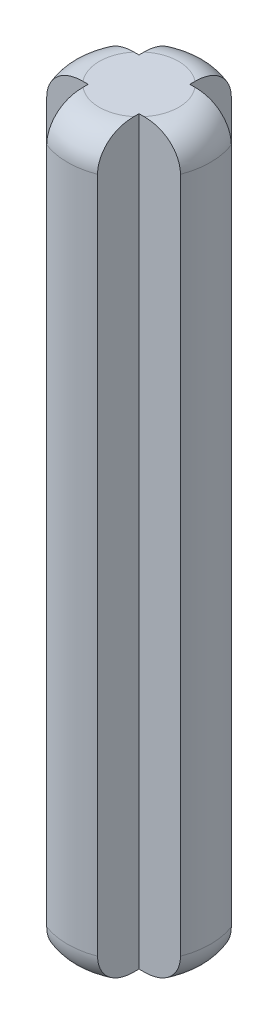
from build123d import *

# Parameters (mm, degrees)
BOSS_EXTRUDE1_DEPTH = 23.3
FILLET1_R           = 1
FILLET2_R           = 1
FILLET3_R           = 1
FILLET4_R           = 1
FILLET20_R          = 1
FILLET21_R          = 1
FILLET22_R          = 1
FILLET23_R          = 1


with BuildPart() as part:
    # Sketch1 → Boss-Extrude1 (new body)
    with BuildSketch(Plane(origin=(0, 0, 0), x_dir=(1, 0, 0), z_dir=(0, 1, 0))):
        with BuildLine():
            Line((-0.8, -0.8), (-0.8, -2.102974084))
            ThreePointArc((-0.8, -2.102974084), (0, -2.25), (0.8, -2.102974084))
            Line((0.8, -2.102974084), (0.8, -0.8))
            Line((0.8, -0.8), (2.102974084, -0.8))
            ThreePointArc((2.102974084, -0.8), (2.25, 0), (2.102974084, 0.8))
            Line((2.102974084, 0.8), (0.8, 0.8))
            Line((0.8, 0.8), (0.8, 2.102974084))
            ThreePointArc((0.8, 2.102974084), (0, 2.25), (-0.8, 2.102974084))
            Line((-0.8, 2.102974084), (-0.8, 0.8))
            Line((-0.8, 0.8), (-2.102974084, 0.8))
            ThreePointArc((-2.102974084, 0.8), (-2.25, 0), (-2.102974084, -0.8))
            Line((-2.102974084, -0.8), (-0.8, -0.8))
        make_face()
    extrude(amount=BOSS_EXTRUDE1_DEPTH)

    # Fillet1
    fillet1_edges = [part.edges().sort_by_distance(p)[0] for p in [
        (-2.25, 0, 0),
    ]]
    fillet(fillet1_edges, radius=FILLET1_R)

    # Fillet2
    fillet2_edges = [part.edges().sort_by_distance(p)[0] for p in [
        (0, 0, 2.25),
    ]]
    fillet(fillet2_edges, radius=FILLET2_R)

    # Fillet3
    fillet3_edges = [part.edges().sort_by_distance(p)[0] for p in [
        (2.25, 0, 0),
    ]]
    fillet(fillet3_edges, radius=FILLET3_R)

    # Fillet4
    fillet4_edges = [part.edges().sort_by_distance(p)[0] for p in [
        (0, 0, -2.25),
    ]]
    fillet(fillet4_edges, radius=FILLET4_R)

    # Fillet20
    fillet20_edges = [part.edges().sort_by_distance(p)[0] for p in [
        (2.25, 23.3, 0),
    ]]
    fillet(fillet20_edges, radius=FILLET20_R)

    # Fillet21
    fillet21_edges = [part.edges().sort_by_distance(p)[0] for p in [
        (0, 23.3, 2.25),
    ]]
    fillet(fillet21_edges, radius=FILLET21_R)

    # Fillet22
    fillet22_edges = [part.edges().sort_by_distance(p)[0] for p in [
        (-2.25, 23.3, 0),
    ]]
    fillet(fillet22_edges, radius=FILLET22_R)

    # Fillet23
    fillet23_edges = [part.edges().sort_by_distance(p)[0] for p in [
        (0, 23.3, -2.25),
    ]]
    fillet(fillet23_edges, radius=FILLET23_R)


solid = part.part
